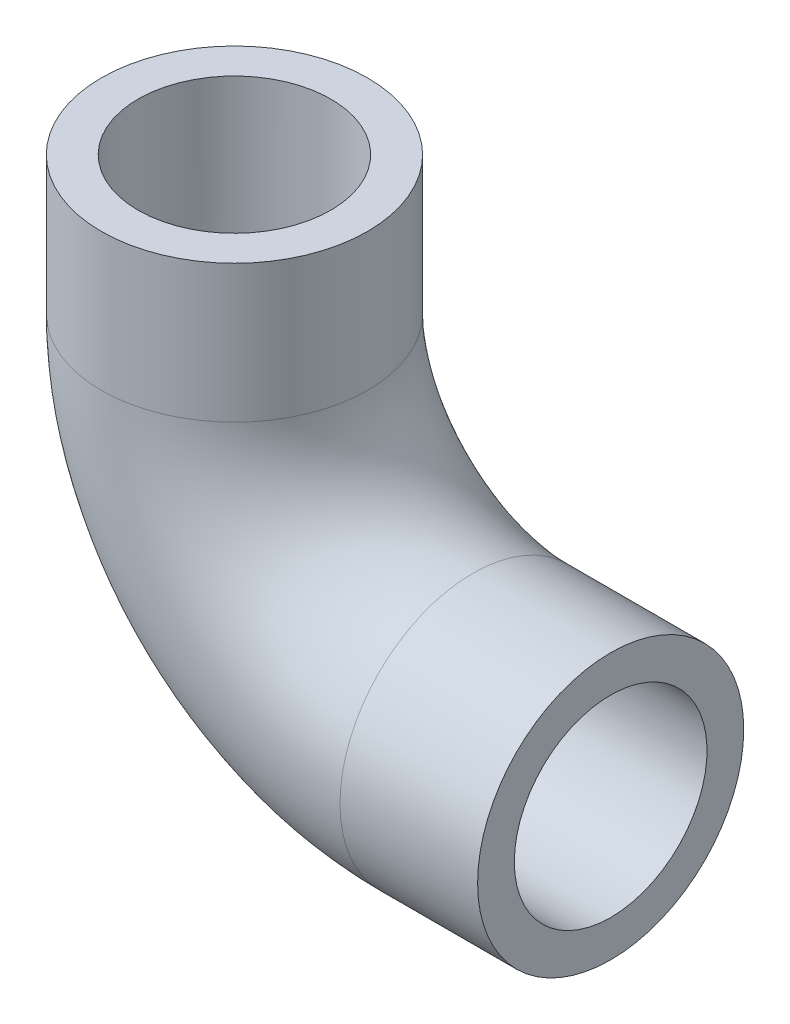
from build123d import *

# Parameters (mm, degrees)
SKETCH2_R   = 145
SKETCH2_R_2 = 105


with BuildPart() as part:
    # Sweep1: sweep along a path in Sketch1
    with BuildLine(Plane.XY) as sweep1_path:
        Line((0, 0), (0, -150))
        ThreePointArc((0, -150), (76.152236891, -333.847763109), (260, -410))
        Line((260, -410), (410, -410))
    # Sketch2 → Sweep1 (sweep)
    with BuildSketch(Plane(origin=(0, 0, 0), x_dir=(1, 0, 0), z_dir=(0, 1, 0))):
        Circle(SKETCH2_R)
        Circle(SKETCH2_R_2, mode=Mode.SUBTRACT)
    sweep(path=sweep1_path.line)


solid = part.part
